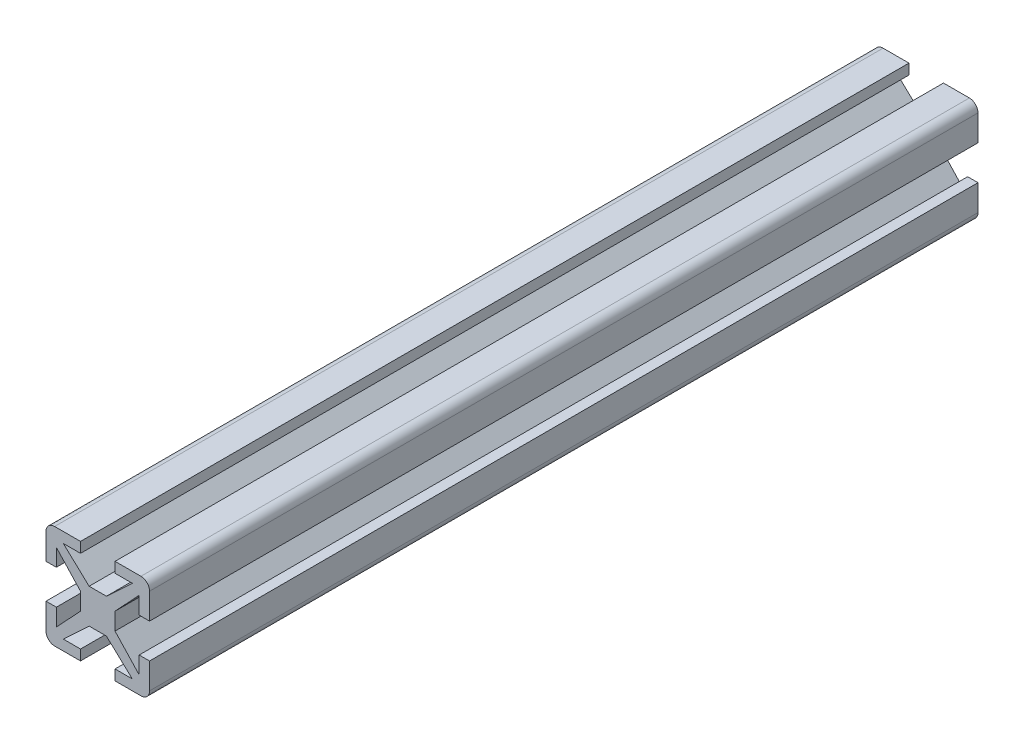
from build123d import *

# Parameters (mm, degrees)
EXTRUSION1_DEPTH             = 48
ENL_V_MAT_EXTRU_1_DEPTH      = 97.374270425
R_P_TITION_CIRCULAIRE1_COUNT = 4


with BuildPart() as part:
    # Esquisse1 → Extrusion1 (new, symmetric)
    with BuildSketch(Plane.XY):
        with BuildLine():
            Line((-6, 5), (-6, -5))
            ThreePointArc((-6, -5), (-5.707106781, -5.707106781), (-5, -6))
            Line((-5, -6), (5, -6))
            ThreePointArc((5, -6), (5.707106781, -5.707106781), (6, -5))
            Line((6, -5), (6, 5))
            ThreePointArc((6, 5), (5.707106781, 5.707106781), (5, 6))
            Line((5, 6), (-5, 6))
            ThreePointArc((-5, 6), (-5.707106781, 5.707106781), (-6, 5))
        make_face()
    extrude(amount=EXTRUSION1_DEPTH, both=True)

    # Esquisse3 → Enlèv. mat.-Extru.1 (cut, through all)
    with BuildSketch(Plane.XY.offset(48)):
        Polygon((6, 2), (4.8, 2), (4.8, 4), (2, 1), (2, -1), (4.8, -4), (4.8, -2), (6, -2), align=None)
    enl_v_mat_extru_1 = extrude(amount=-ENL_V_MAT_EXTRU_1_DEPTH, mode=Mode.SUBTRACT)

    # Répétition circulaire1: Enlèv. mat.-Extru.1 ×4 about axis
    r_p_tition_circulaire1_axis = Axis((0, 0, -1), (0, 0, 1))
    for i in range(1, R_P_TITION_CIRCULAIRE1_COUNT):
        add(enl_v_mat_extru_1.rotate(r_p_tition_circulaire1_axis, i * 360 / R_P_TITION_CIRCULAIRE1_COUNT), mode=Mode.SUBTRACT)


solid = part.part
